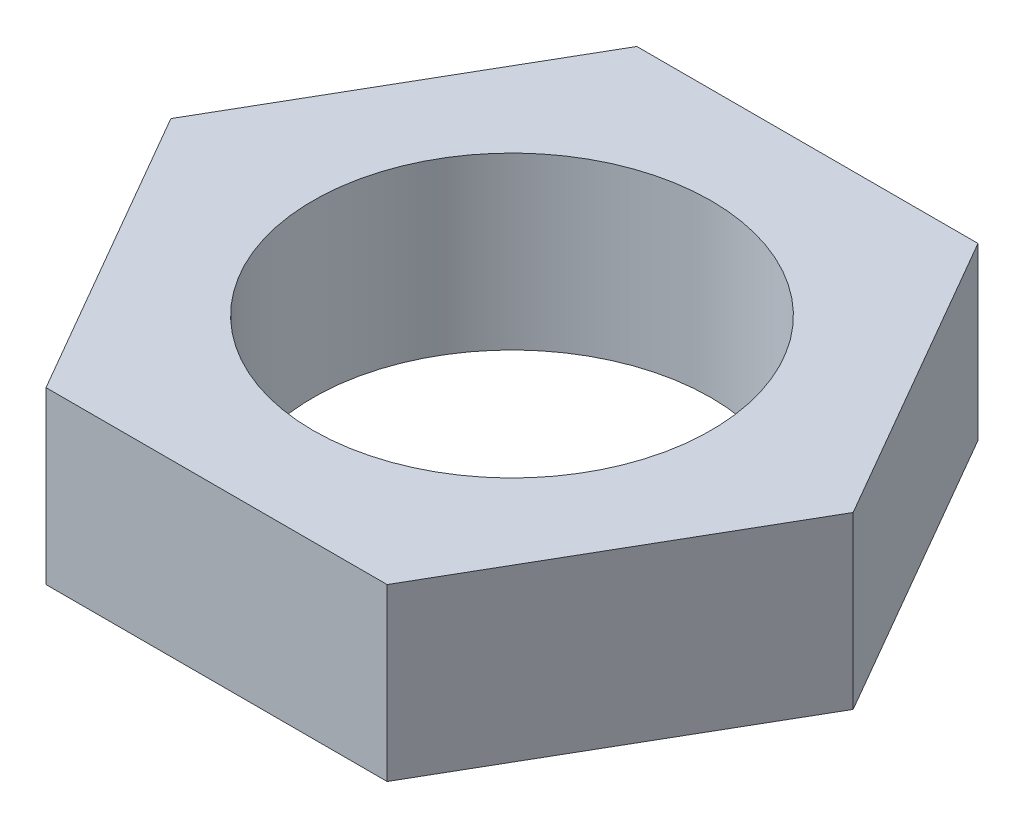
from build123d import *

# Parameters (mm, degrees)
BOSS_EXTRUDE1_DEPTH = 3
SKETCH2_R           = 3.5
CUT_EXTRUDE1_DEPTH  = 4


with BuildPart() as part:
    # Sketch1 → Boss-Extrude1 (new body)
    with BuildSketch(Plane(origin=(0, 0, 0), x_dir=(1, 0, 0), z_dir=(0, 1, 0))):
        Polygon((6, 0), (3, 5.196152423), (-3, 5.196152423), (-6, 0), (-3, -5.196152423), (3, -5.196152423), align=None)
    extrude(amount=BOSS_EXTRUDE1_DEPTH)

    # Sketch2 → Cut-Extrude1 (cut, through all)
    with BuildSketch(Plane(origin=(0, 3, 0), x_dir=(1, 0, 0), z_dir=(0, 1, 0))):
        Circle(SKETCH2_R)
    extrude(amount=-CUT_EXTRUDE1_DEPTH, mode=Mode.SUBTRACT)


solid = part.part
